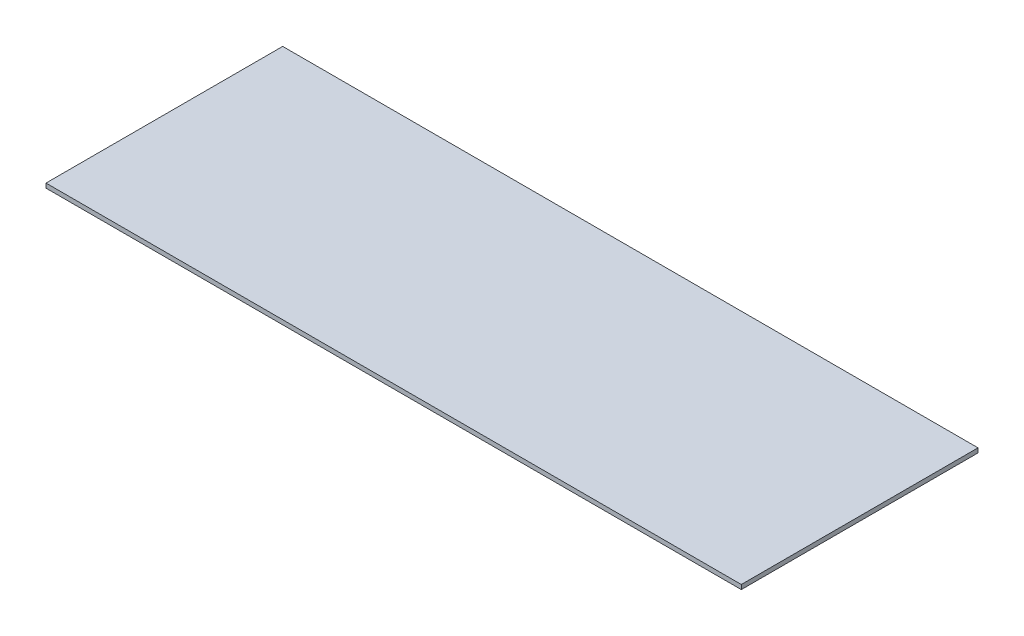
from build123d import *

# Parameters (mm, degrees)
SKETCH1_W      = 470
SKETCH1_H      = 160
EXTRUDE1_DEPTH = 3


with BuildPart() as part:
    # Sketch1 → Extrude1 (new body)
    with BuildSketch(Plane(origin=(0, 0, 0), x_dir=(1, 0, 0), z_dir=(0, 1, 0))):
        Rectangle(SKETCH1_W, SKETCH1_H)
    extrude(amount=EXTRUDE1_DEPTH)


solid = part.part
